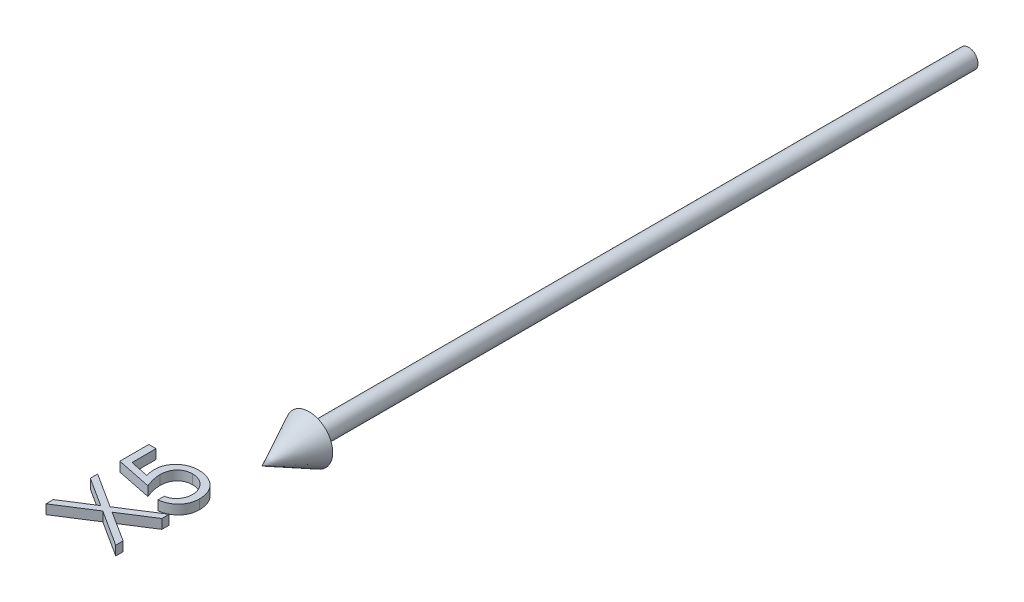
from build123d import *

# Parameters (mm, degrees)
BOSS_EXTRUDE1_DEPTH        = 1
BOSS_EXTRUDE1_DEPTH_BACK   = 1
BOSS_EXTRUDE1_2_DEPTH      = 1
BOSS_EXTRUDE1_2_DEPTH_BACK = 1


with BuildPart() as part:
    # Sketch2 → Revolve1 (revolve)
    with BuildSketch(Plane(origin=(0, 0, 0), x_dir=(1, 0, 0), z_dir=(0, 1, 0))):
        Polygon((0, -150), (5, -140), (2, -140), (2, 0), (0, 0), align=None)
    revolve(axis=Axis((0, 0, -41.949952025), (0, 0, 1)))


with BuildPart() as body_2:
    # Sketch3 → Boss-Extrude1 (new, two sides: drawn at the far end of the back side and taken through both)
    with BuildSketch(Plane(origin=(0, 0, 0), x_dir=(1, 0, 0), z_dir=(0, 1, 0)).offset(-BOSS_EXTRUDE1_DEPTH_BACK)):
        with BuildLine():
            Line((-15, -159.038461538), (-13.461538462, -159.038461538))
            Line((-13.461538462, -159.038461538), (-13.461538462, -164.140625))
            Line((-13.461538462, -164.140625), (-9.516225962, -164.948918269))
            add(Edge.make_bspline(
                [(-9.516225962, -164.948918269), (-9.560069984, -164.790107379), (-9.645010842, -164.482436397), (-9.739321287, -164.028322707), (-9.79617319, -163.597213264), (-9.803935949, -163.317461676), (-9.807692308, -163.182091346)],
                knots=[0, 0, 0, 0, 1.100273476, 2.13160584, 3.095893838, 4, 4, 4, 4], degree=3))
            add(Edge.make_bspline(
                [(-9.807692308, -163.182091346), (-9.804186599, -163.014558858), (-9.797293501, -162.685148127), (-9.727174227, -162.203929676), (-9.625612174, -161.742241094), (-9.469136601, -161.30689917), (-9.278052021, -160.891016359), (-9.037376819, -160.50173494), (-8.756389114, -160.133591337), (-8.436536051, -159.789129967), (-8.080861965, -159.478102832), (-7.696859719, -159.207830503), (-7.292908883, -158.971932896), (-6.859541679, -158.787953931), (-6.40493156, -158.637809151), (-5.923830784, -158.538803307), (-5.420510455, -158.472671692), (-5.076344015, -158.465298377), (-4.900841346, -158.461538462)],
                knots=[0, 0, 0, 0, 1.052805225, 2.070078116, 3.052532748, 4.020689046, 4.973125432, 5.925915817, 6.89216474, 7.881560752, 8.877013184, 9.857446635, 10.830895175, 11.812622661, 12.812548702, 13.836681939, 14.896847428, 16, 16, 16, 16], degree=3))
            add(Edge.make_bspline(
                [(-4.900841346, -158.461538462), (-4.778604023, -158.464391352), (-4.535781307, -158.470058578), (-4.175152107, -158.498814881), (-3.822210194, -158.554393705), (-3.477602628, -158.628108493), (-3.141006659, -158.726514095), (-2.810537702, -158.841617332), (-2.489814366, -158.984683039), (-2.177420147, -159.143287356), (-1.876930293, -159.318911746), (-1.595549591, -159.51639747), (-1.326856873, -159.721596515), (-1.078831903, -159.945814355), (-0.850512632, -160.186501755), (-0.640770308, -160.442319507), (-0.445840686, -160.710947305), (-0.273693897, -160.996616006), (-0.115280519, -161.292940019), (0.014677308, -161.604204053), (0.130865337, -161.923321274), (0.223477584, -162.254885045), (0.296045678, -162.598144237), (0.345333966, -162.953664705), (0.381232984, -163.319581862), (0.383480228, -163.56761763), (0.384615385, -163.692908654)],
                knots=[0, 0, 0, 0, 1.056393913, 2.098511576, 3.122979385, 4.141471433, 5.141222888, 6.151259816, 7.162667642, 8.172852865, 9.177685681, 10.166741883, 11.141342384, 12.097242845, 13.052202613, 14.005160326, 14.953864445, 15.917140761, 16.884916217, 17.854238259, 18.828761908, 19.81781811, 20.826036654, 21.857789401, 22.917898972, 24, 24, 24, 24], degree=3))
            add(Edge.make_bspline(
                [(0.384615385, -163.692908654), (0.381646688, -163.842365617), (0.375806128, -164.136404537), (0.314983266, -164.567261294), (0.227294847, -164.98155407), (0.097379703, -165.377507265), (-0.072734928, -165.75346953), (-0.274856842, -166.114824558), (-0.515479886, -166.457093514), (-0.792403166, -166.777936406), (-1.096683506, -167.072862145), (-1.423725263, -167.340302978), (-1.773944943, -167.575432851), (-2.146203734, -167.779104688), (-2.539841347, -167.95261453), (-2.956070668, -168.088979128), (-3.392788289, -168.199025207), (-3.693445734, -168.245583276), (-3.846153846, -168.269230769)],
                knots=[0, 0, 0, 0, 1.046872515, 2.059598001, 3.044168548, 4.012104806, 4.973680974, 5.932408326, 6.910122221, 7.900780896, 8.89867654, 9.876692837, 10.858029398, 11.85084981, 12.847361615, 13.868568023, 14.917415949, 16, 16, 16, 16], degree=3))
            Line((-3.846153846, -168.269230769), (-3.846153846, -166.923076923))
            add(Edge.make_bspline(
                [(-3.846153846, -166.923076923), (-3.703097014, -166.889975256), (-3.428133839, -166.826352013), (-3.042054853, -166.686337335), (-2.697889799, -166.516807482), (-2.393534398, -166.310519181), (-2.123417488, -166.071404628), (-1.885256014, -165.793446318), (-1.670131171, -165.483593118), (-1.490506155, -165.13909721), (-1.339196302, -164.774948369), (-1.231216621, -164.395992233), (-1.165854198, -164.007682718), (-1.1578639, -163.746242921), (-1.153846154, -163.614783654)],
                knots=[0, 0, 0, 0, 1.13623081, 2.183898708, 3.172478118, 4.09966615, 5.022692284, 5.957376522, 6.927682873, 7.937366477, 8.960015386, 9.976409503, 10.982481913, 12, 12, 12, 12], degree=3))
            add(Edge.make_bspline(
                [(-1.153846154, -163.614783654), (-1.157393206, -163.486401212), (-1.16437738, -163.233615134), (-1.217265273, -162.861410111), (-1.300858252, -162.503110451), (-1.417967227, -162.158080124), (-1.572895535, -161.828014544), (-1.763216032, -161.51338039), (-1.984180393, -161.209695419), (-2.236734594, -160.924952163), (-2.51520754, -160.664225413), (-2.812959591, -160.433838444), (-3.130605369, -160.241938327), (-3.462632597, -160.080220468), (-3.81268371, -159.957420683), (-4.179117276, -159.86981646), (-4.562838631, -159.818374784), (-4.824564243, -159.811298298), (-4.957932692, -159.807692308)],
                knots=[0, 0, 0, 0, 1.027268864, 2.022700798, 3.002744649, 3.968653148, 4.933396556, 5.915045722, 6.907600446, 7.935526002, 8.956456544, 9.95700807, 10.942805781, 11.92166854, 12.907987664, 13.905483474, 14.932689774, 16, 16, 16, 16], degree=3))
            add(Edge.make_bspline(
                [(-4.957932692, -159.807692308), (-5.078271566, -159.810428617), (-5.312824471, -159.815761966), (-5.657184407, -159.861932413), (-5.983536333, -159.939059418), (-6.293300258, -160.048872604), (-6.585485797, -160.18592297), (-6.859449051, -160.357993861), (-7.117765997, -160.557758345), (-7.35378905, -160.790978855), (-7.571970379, -161.044674492), (-7.757289776, -161.325361455), (-7.914888843, -161.625546446), (-8.044013421, -161.945785751), (-8.146871035, -162.286473834), (-8.217957334, -162.647794189), (-8.260494301, -163.029829166), (-8.266264657, -163.291153355), (-8.269230769, -163.425480769)],
                knots=[0, 0, 0, 0, 1.045723156, 2.038222538, 3.013889863, 3.95567481, 4.890389958, 5.81331128, 6.76251276, 7.723027653, 8.692928204, 9.666105983, 10.639751036, 11.635719707, 12.66315958, 13.728667616, 14.832476222, 16, 16, 16, 16], degree=3))
            add(Edge.make_bspline(
                [(-8.269230769, -163.425480769), (-8.266742521, -163.541747607), (-8.261604921, -163.78180913), (-8.223777077, -164.150049816), (-8.16275153, -164.537014343), (-8.078810469, -164.941219324), (-7.968962997, -165.363878644), (-7.837329423, -165.804100362), (-7.679949429, -166.262810076), (-7.561097084, -166.571886037), (-7.5, -166.730769231)],
                knots=[0, 0, 0, 0, 0.817624296, 1.688186739, 2.600797293, 3.572016777, 4.590301741, 5.671205678, 6.80286297, 8, 8, 8, 8], degree=3))
            Line((-7.5, -166.730769231), (-15, -165.192307692))
            Line((-15, -165.192307692), (-15, -159.038461538))
        make_face()
    extrude(amount=BOSS_EXTRUDE1_DEPTH + BOSS_EXTRUDE1_DEPTH_BACK)


with BuildPart() as body_3:
    # Sketch3 → Boss-Extrude1 2 (new, two sides: drawn at the far end of the back side and taken through both)
    with BuildSketch(Plane(origin=(0, 0, 0), x_dir=(1, 0, 0), z_dir=(0, 1, 0)).offset(-BOSS_EXTRUDE1_2_DEPTH_BACK)):
        Polygon((-15, -180.865384615), (-15, -179.311899038), (-8.864182692, -175.384615385), (-15, -171.457331731), (-15, -169.903846154), (-7.650240385, -174.606370192), (0, -169.711538462), (0, -171.265024038), (-6.436298077, -175.384615385), (0, -179.504206731), (0, -181.057692308), (-7.650240385, -176.159855769), align=None)
    extrude(amount=BOSS_EXTRUDE1_2_DEPTH + BOSS_EXTRUDE1_2_DEPTH_BACK)


solid = Compound([part.part, body_2.part, body_3.part])
